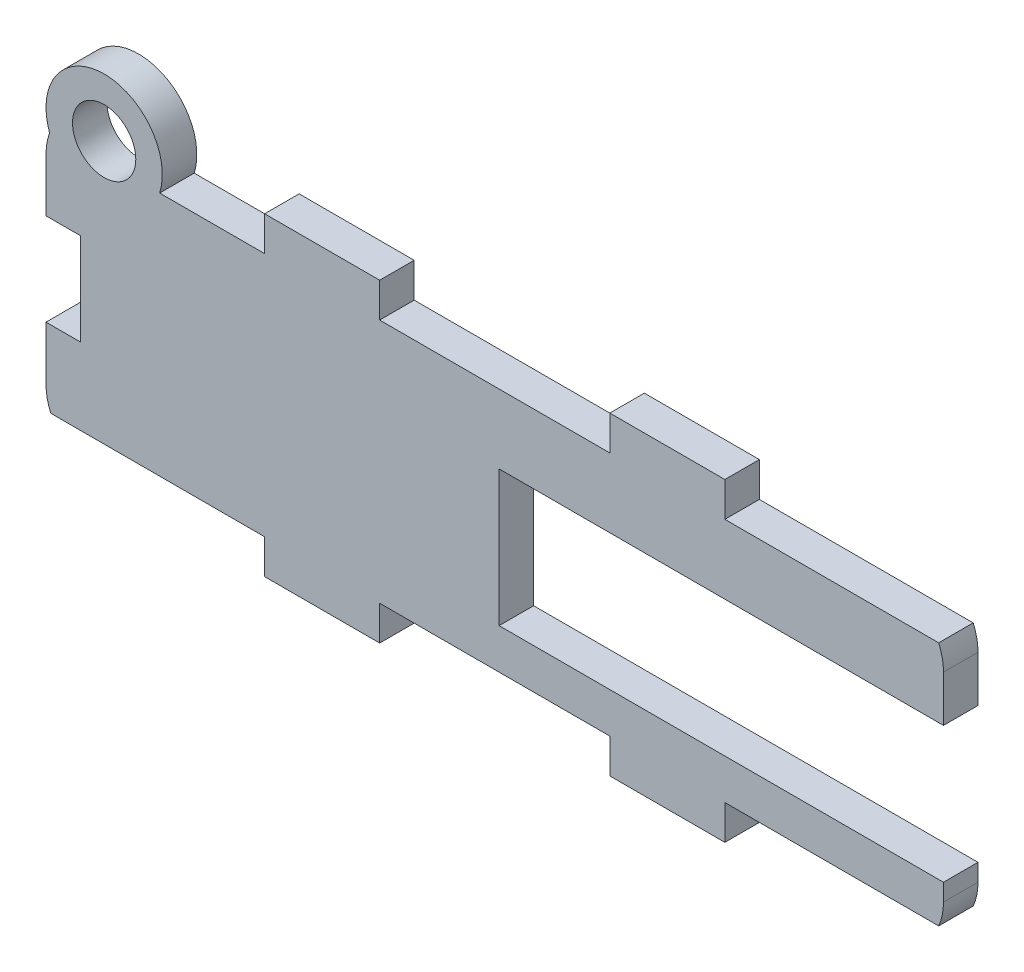
from build123d import *

# Parameters (mm, degrees)
BOSS_EXTRUDE1_DEPTH = 3
CUT_EXTRUDE1_REACH  = 5
SKETCH3_R           = 5.053902861
SKETCH3_R_2         = 2.749769833
BOSS_EXTRUDE2_DEPTH = 3
CUT_EXTRUDE2_REACH  = 5
SKETCH5_W           = 3
SKETCH5_H           = 8
CUT_EXTRUDE3_DEPTH  = 3


with BuildPart() as part:
    # Sketch1 → Boss-Extrude1 (new body)
    with BuildSketch(Plane.XY):
        with BuildLine():
            Line((-7, -3), (3, -3))
            Line((3, -3), (3, 0))
            Line((3, 0), (23, 0))
            Line((23, 0), (23, -3))
            Line((23, -3), (33, -3))
            Line((33, -3), (33, 0))
            Line((33, 0), (51.582575695, 0))
            ThreePointArc((51.582575695, 0), (51.894531565, 0.978451782), (52, 2))
            Line((52, 2), (52, 19.311841589))
            ThreePointArc((52, 19.311841589), (51.894531565, 20.333389808), (51.582575695, 21.311841589))
            Line((51.582575695, 21.311841589), (33, 21.311841589))
            Line((33, 21.311841589), (33, 24.311841589))
            Line((33, 24.311841589), (23, 24.311841589))
            Line((23, 24.311841589), (23, 21.311841589))
            Line((23, 21.311841589), (3, 21.311841589))
            Line((3, 21.311841589), (3, 24.311841589))
            Line((3, 24.311841589), (-7, 24.311841589))
            Line((-7, 24.311841589), (-7, 21.311841589))
            Line((-7, 21.311841589), (-25.582575695, 21.311841589))
            ThreePointArc((-25.582575695, 21.311841589), (-25.894531565, 20.333389808), (-26, 19.311841589))
            Line((-26, 19.311841589), (-26, 2))
            ThreePointArc((-26, 2), (-25.894531565, 0.978451782), (-25.582575695, 0))
            Line((-25.582575695, 0), (-7, 0))
            Line((-7, 0), (-7, -3))
        make_face()
    extrude(amount=BOSS_EXTRUDE1_DEPTH)

    # Sketch2 → Cut-Extrude1 (cut, up to next)
    with BuildSketch(Plane.XY.offset(3), mode=Mode.PRIVATE) as cut_extrude1_sk1:
        Polygon((13.38, 3.5), (13.38, 15.3), (23.54, 15.3), (52, 15.3), (52, 3.5), align=None)
    cut_extrude1_tool1 = extrude(cut_extrude1_sk1.sketch, amount=-CUT_EXTRUDE1_REACH, mode=Mode.PRIVATE) & part.part
    add(cut_extrude1_tool1.solids().sort_by_distance((32.69, 9.4, 3))[0], mode=Mode.SUBTRACT)

    # Sketch3 → Boss-Extrude2 (add)
    with BuildSketch(Plane.XY.offset(3)):
        with Locations((-20.946097139, 22.811841589)):
            Circle(SKETCH3_R)
        with Locations((-20.946097139, 22.811841589)):
            Circle(SKETCH3_R_2, mode=Mode.SUBTRACT)
    extrude(amount=-BOSS_EXTRUDE2_DEPTH)

    # Sketch4 → Cut-Extrude2 (cut, up to next)
    with BuildSketch(Plane.XY.offset(3), mode=Mode.PRIVATE) as cut_extrude2_sk1:
        with BuildLine():
            Line((-23.250708633, 21.311841589), (-18.641485645, 21.311841589))
            ThreePointArc((-18.641485645, 21.311841589), (-20.946097139, 20.062071756), (-23.250708633, 21.311841589))
        make_face()
    cut_extrude2_tool1 = extrude(cut_extrude2_sk1.sketch, amount=-CUT_EXTRUDE2_REACH, mode=Mode.PRIVATE) & part.part
    add(cut_extrude2_tool1.solids().sort_by_distance((-20.946097, 20.800705, 3))[0], mode=Mode.SUBTRACT)

    # Sketch5 → Cut-Extrude3 (cut)
    with BuildSketch(Plane.XY.offset(3)):
        with Locations((-24.5, 10.655920795)):
            Rectangle(SKETCH5_W, SKETCH5_H)
    extrude(amount=-CUT_EXTRUDE3_DEPTH, mode=Mode.SUBTRACT)


solid = part.part
